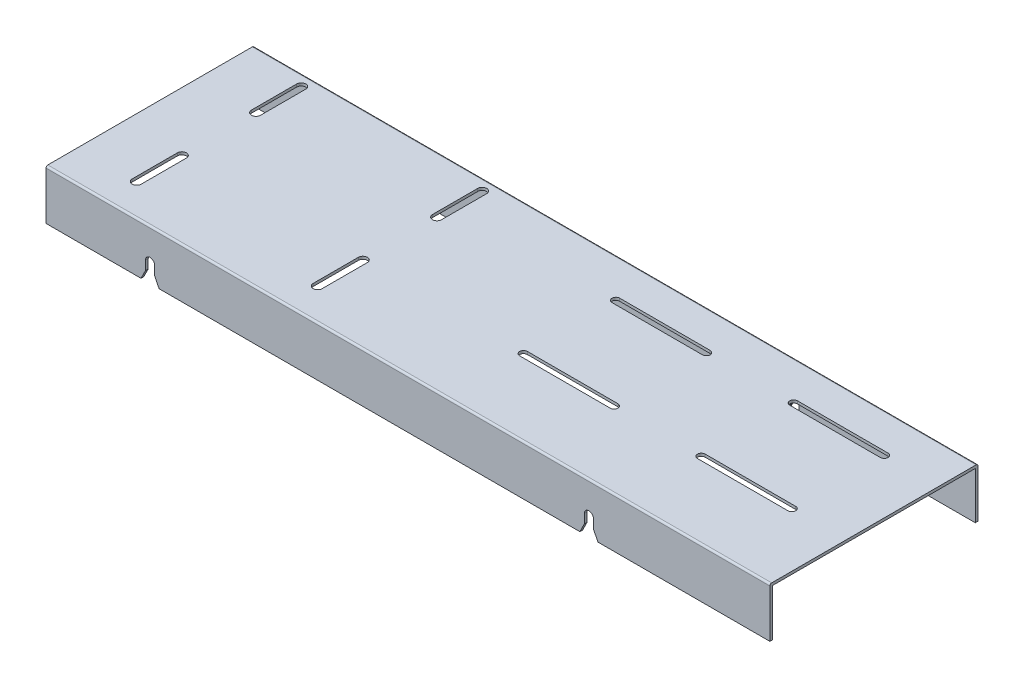
from build123d import *

# Parameters (mm, degrees)
BOSS_EXTRU_1_DEPTH      = 800
ENL_V_MAT_EXTRU_1_DEPTH = 30
ENL_V_MAT_EXTRU_2_DEPTH = 30
ENL_V_MAT_EXTRU_4_DEPTH = 300
CONG_1_R                = 2


with BuildPart() as part:
    # Esquisse1 → Boss.-Extru.1 (new body)
    with BuildSketch(Plane(origin=(0, 0, 0), x_dir=(0, 0, -1), z_dir=(1, 0, 0))):
        Polygon((0, 0), (230, 0), (230, -55), (227, -55), (227, -3), (3, -3), (3, -55), (0, -55), align=None)
    extrude(amount=BOSS_EXTRU_1_DEPTH)

    # Esquisse2 → Enlèv. mat.-Extru.1 (cut)
    with BuildSketch(Plane(origin=(0, 0, 0), x_dir=(1, 0, 0), z_dir=(0, 1, 0))):
        with BuildLine():
            Line((443.5, 190.5), (543.5, 190.5))
            ThreePointArc((543.5, 190.5), (547.75, 186.25), (543.5, 182))
            Line((543.5, 182), (443.5, 182))
            ThreePointArc((443.5, 182), (439.25, 186.25), (443.5, 190.5))
        make_face()
        with BuildLine():
            Line((640, 190.5), (740, 190.5))
            ThreePointArc((740, 190.5), (744.25, 186.25), (740, 182))
            Line((740, 182), (640, 182))
            ThreePointArc((640, 182), (635.75, 186.25), (640, 190.5))
        make_face()
        with BuildLine():
            Line((443.5, 88.5), (543.5, 88.5))
            ThreePointArc((543.5, 88.5), (547.75, 84.25), (543.5, 80))
            Line((543.5, 80), (443.5, 80))
            ThreePointArc((443.5, 80), (439.25, 84.25), (443.5, 88.5))
        make_face()
        with BuildLine():
            Line((640, 88.5), (740, 88.5))
            ThreePointArc((740, 88.5), (744.25, 84.25), (740, 80))
            Line((740, 80), (640, 80))
            ThreePointArc((640, 80), (635.75, 84.25), (640, 88.5))
        make_face()
    extrude(amount=-ENL_V_MAT_EXTRU_1_DEPTH, mode=Mode.SUBTRACT)

    # Esquisse3 → Enlèv. mat.-Extru.2 (cut)
    with BuildSketch(Plane(origin=(0, 0, 0), x_dir=(1, 0, 0), z_dir=(0, 1, 0))):
        with BuildLine():
            Line((70, 217.1), (70, 167.1))
            ThreePointArc((70, 167.1), (65, 162.1), (60, 167.1))
            Line((60, 167.1), (60, 217.1))
            ThreePointArc((60, 217.1), (65, 222.1), (70, 217.1))
        make_face()
        with BuildLine():
            Line((270, 217.1), (270, 167.1))
            ThreePointArc((270, 167.1), (265, 162.1), (260, 167.1))
            Line((260, 167.1), (260, 217.1))
            ThreePointArc((260, 217.1), (265, 222.1), (270, 217.1))
        make_face()
        with BuildLine():
            Line((270, 85.2), (270, 35.2))
            ThreePointArc((270, 35.2), (265, 30.2), (260, 35.2))
            Line((260, 35.2), (260, 85.2))
            ThreePointArc((260, 85.2), (265, 90.2), (270, 85.2))
        make_face()
        with BuildLine():
            Line((60, 35.2), (60, 85.2))
            ThreePointArc((60, 85.2), (65, 90.2), (70, 85.2))
            Line((70, 85.2), (70, 35.2))
            ThreePointArc((70, 35.2), (65, 30.2), (60, 35.2))
        make_face()
    extrude(amount=-ENL_V_MAT_EXTRU_2_DEPTH, mode=Mode.SUBTRACT)

    # Esquisse6 → Enlèv. mat.-Extru.4 (cut)
    with BuildSketch(Plane.XY):
        with BuildLine():
            Line((595, -55), (605, -55))
            Line((605, -55), (610, -55))
            Line((610, -55), (605, -45))
            Line((605, -45), (605, -35))
            ThreePointArc((605, -35), (600, -30), (595, -35))
            Line((595, -35), (595, -45))
            Line((595, -45), (590, -55))
            Line((590, -55), (595, -55))
        make_face()
        with BuildLine():
            Line((110, -45), (105, -55))
            Line((105, -55), (110, -55))
            Line((110, -55), (120, -55))
            Line((120, -55), (125, -55))
            Line((125, -55), (120, -45))
            Line((120, -45), (120, -35))
            ThreePointArc((120, -35), (115, -30), (110, -35))
            Line((110, -35), (110, -45))
        make_face()
    extrude(amount=-ENL_V_MAT_EXTRU_4_DEPTH, mode=Mode.SUBTRACT)

    # Congé1
    cong_1_edges = [part.edges().sort_by_distance(p)[0] for p in [
        (400, 0, 0),
        (400, 0, -230),
    ]]
    fillet(cong_1_edges, radius=CONG_1_R)


solid = part.part
